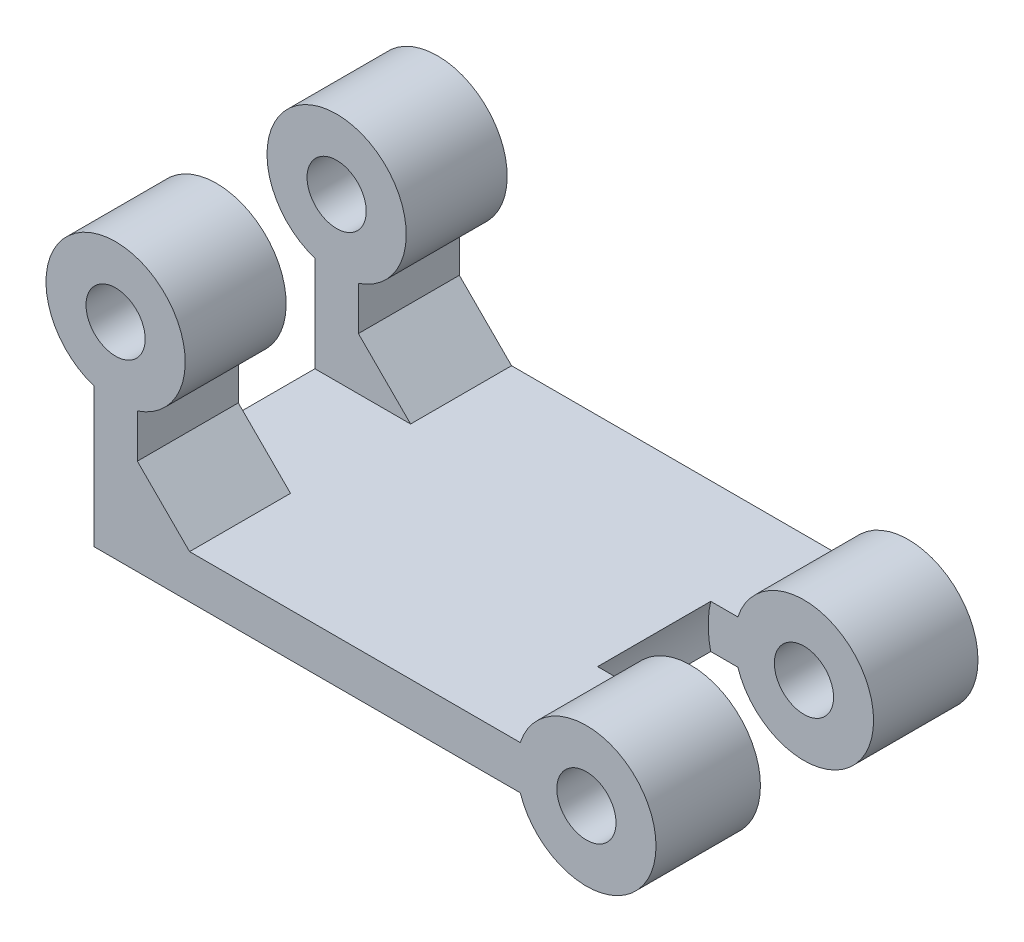
from build123d import *

# Parameters (mm, degrees)
SKETCH_2_R             = 4
SKETCH_2_R_2           = 1.7
EXTRUDE_1_DEPTH        = 6
PATTERN_LINEAR_1_COUNT = 2
PATTERN_LINEAR_1_PITCH = 12.5
SKETCH_3_R             = 1.7
EXTRUDE_2_DEPTH        = 18.5
SKETCH_4_R             = 5.5
CUT_EXTRUDE_1_DEPTH    = 6.5
SKETCH_9_W             = 14.956687691
SKETCH_9_H             = 17.867271405
CUT_EXTRUDE_3_DEPTH    = 3.45
CHAMFER_1_SIZE         = 3


with BuildPart() as part:
    # Эскиз2 → Бобышка-Вытянуть1 (new body)
    with BuildSketch(Plane.XY):
        Circle(SKETCH_2_R)
        Circle(SKETCH_2_R_2, mode=Mode.SUBTRACT)
    extrude(amount=EXTRUDE_1_DEPTH)


with BuildPart() as pattern_linear_1_1:
    # Линейный массив1: pattern copy
    add(part.part.moved(Location(Vector(0, 0, 1) * (1 * PATTERN_LINEAR_1_PITCH))))


with BuildPart() as part_1:
    add(part.part)

    add(pattern_linear_1_1.part)  # Бобышка-Вытянуть2 merges Линейный массив1_1
    # Эскиз3 → Бобышка-Вытянуть2 (add)
    with BuildSketch(Plane(origin=(0, 0, 0), x_dir=(-1, 0, 0), z_dir=(0, 0, -1))):
        with BuildLine():
            Line((3.799671038, 1.25), (25.799671038, 1.25))
            Line((25.799671038, 1.25), (25.799671038, 6.75))
            ThreePointArc((25.799671038, 6.75), (27.049671038, 14.549671038), (28.299671038, 6.75))
            Line((28.299671038, 6.75), (28.299671038, -1.25))
            Line((28.299671038, -1.25), (25.799671038, -1.25))
            Line((25.799671038, -1.25), (3.799671038, -1.25))
            Line((3.799671038, -1.25), (3.799671038, 1.25))
        make_face()
        with Locations((27.049671038, 10.549671038)):
            Circle(SKETCH_3_R, mode=Mode.SUBTRACT)
    extrude(amount=-EXTRUDE_2_DEPTH)

    # Эскиз4 → Вырез-Вытянуть1 (cut)
    with BuildSketch(Plane.XY.offset(6)):
        Circle(SKETCH_4_R)
    extrude(amount=CUT_EXTRUDE_1_DEPTH, mode=Mode.SUBTRACT)

    # Эскиз9 → Вырез-Вытянуть3 (cut)
    with BuildSketch(Plane(origin=(0, 0, 9.25), x_dir=(-1, 0, 0), z_dir=(0, 0, -1))):
        with Locations((27.795829792, 10.183635703)):
            Rectangle(SKETCH_9_W, SKETCH_9_H)
    cut_extrude_3 = extrude(amount=CUT_EXTRUDE_3_DEPTH, mode=Mode.SUBTRACT)

    # Зеркальное отражение1: Вырез-Вытянуть3 across plane
    add(cut_extrude_3.mirror(Plane(origin=(0, 0, 9.25), x_dir=(1, 0, 0), z_dir=(0, 0, -1))), mode=Mode.SUBTRACT)

    # Фаска1
    chamfer_1_edges = [part_1.edges().sort_by_distance(p)[0] for p in [
        (-25.799671038, 1.25, 15.6),
        (-25.799671038, 1.25, 2.9),
    ]]
    chamfer(chamfer_1_edges, length=CHAMFER_1_SIZE)


solid = part_1.part
